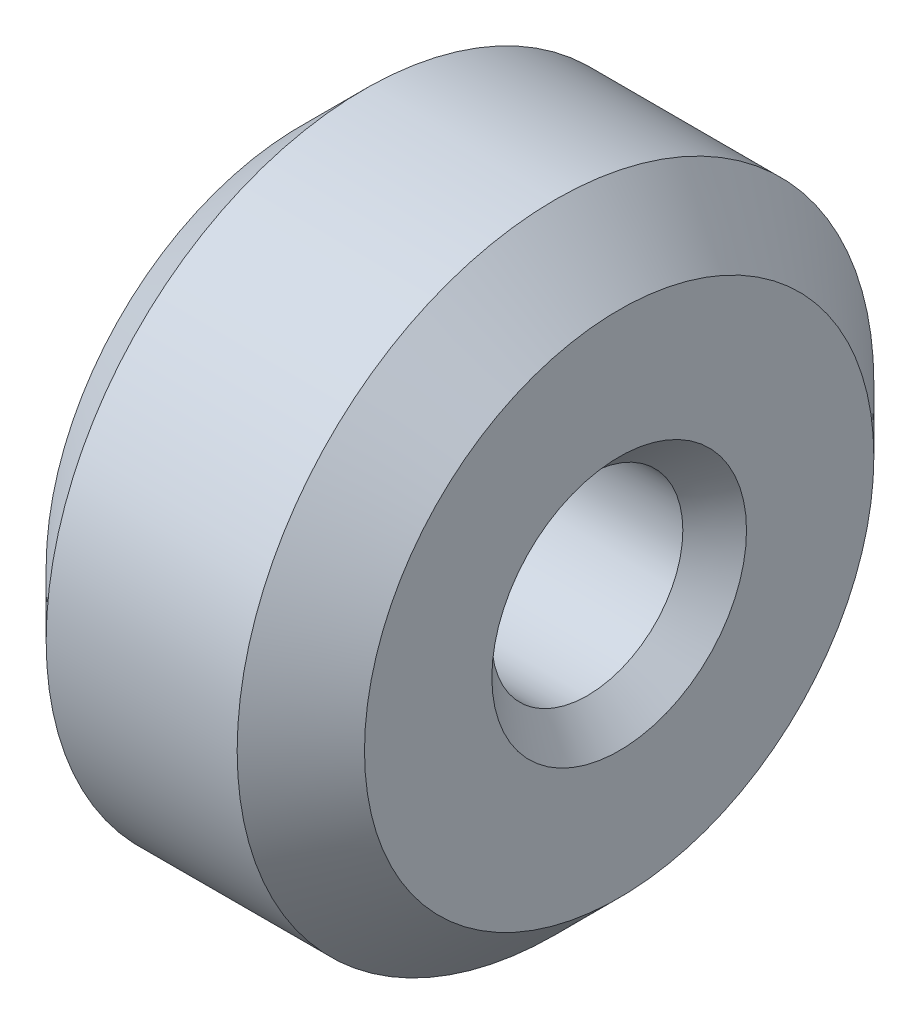
from build123d import *

# Parameters (mm, degrees)
SKETCH1_W     = 10
SKETCH1_H     = 7
CHAMFER1_SIZE = 2
CHAMFER2_SIZE = 1


with BuildPart() as part:
    # Sketch1 → Revolve2 (revolve)
    with BuildSketch(Plane.XY):
        with Locations((5, 6.5)):
            Rectangle(SKETCH1_W, SKETCH1_H)
    revolve(axis=Axis((0, 0, 0), (1, 0, 0)))

    # Chamfer1
    chamfer1_edges = [part.edges().sort_by_distance(p)[0] for p in [
        (0, -10, 0),
        (10, -10, 0),
    ]]
    chamfer(chamfer1_edges, length=CHAMFER1_SIZE)

    # Chamfer2
    chamfer2_edges = [part.edges().sort_by_distance(p)[0] for p in [
        (10, -3, 0),
    ]]
    chamfer(chamfer2_edges, length=CHAMFER2_SIZE)


solid = part.part
